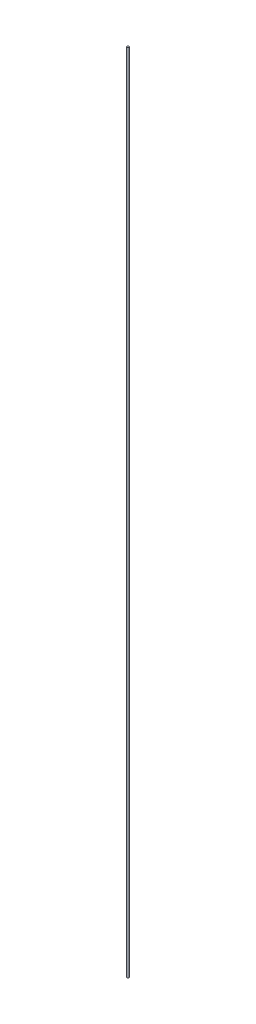
from build123d import *

# Parameters (mm, degrees)
SKETCH_1_R      = 1
EXTRUDE_1_DEPTH = 800


with BuildPart() as part:
    # 草图1 → 凸台-拉伸1 (new body)
    with BuildSketch(Plane(origin=(0, 0, 0), x_dir=(1, 0, 0), z_dir=(0, 1, 0))):
        Circle(SKETCH_1_R)
    extrude(amount=EXTRUDE_1_DEPTH)


solid = part.part
